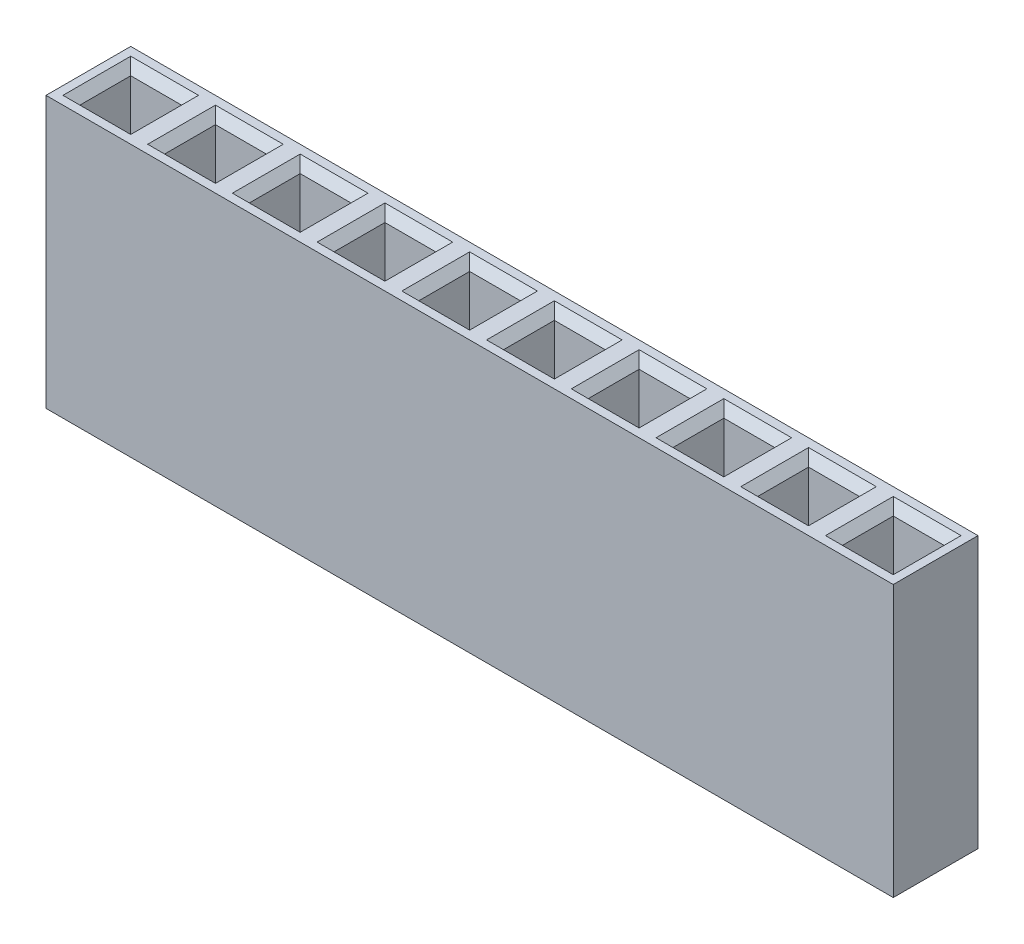
from build123d import *

# Parameters (mm, degrees)
SKETCH1_W                  = 2.5
SKETCH1_H                  = 8
BOSS_EXTRUDE1_DEPTH        = 2.5
SKETCH2_W                  = 1.5
SKETCH2_H                  = 1.5
CUT_EXTRUDE2_DEPTH         = 7
CHAMFER3_SIZE              = 0.25
LPATTERN2_COUNT            = 10
LPATTERN2_PITCH            = 2.5
CHAMFER3_OF_LPATTERN2_SIZE = 0.25


with BuildPart() as part:
    # Sketch1 → Boss-Extrude1 (new body)
    with BuildSketch(Plane.XY):
        Rectangle(SKETCH1_W, SKETCH1_H)
    boss_extrude1 = extrude(amount=BOSS_EXTRUDE1_DEPTH)

    # Sketch2 → Cut-Extrude2 (cut)
    with BuildSketch(Plane(origin=(0, 4, 0), x_dir=(1, 0, 0), z_dir=(0, 1, 0))):
        with Locations((0, -1.25)):
            Rectangle(SKETCH2_W, SKETCH2_H)
    cut_extrude2 = extrude(amount=-CUT_EXTRUDE2_DEPTH, mode=Mode.SUBTRACT)

    # Chamfer3
    chamfer3_edges = [part.edges().sort_by_distance(p)[0] for p in [
        (0, 4, 2),
        (0.75, 4, 1.25),
        (0, 4, 0.5),
        (-0.75, 4, 1.25),
    ]]
    chamfer(chamfer3_edges, length=CHAMFER3_SIZE)

    # LPattern2: Boss-Extrude1, Cut-Extrude2 ×10
    with Locations(*[(i * LPATTERN2_PITCH, 0, 0) for i in range(1, LPATTERN2_COUNT)]):
        add(boss_extrude1)
        add(cut_extrude2, mode=Mode.SUBTRACT)

    # Chamfer3 of LPattern2
    chamfer3_of_lpattern2_edges = [part.edges().sort_by_distance(p)[0] for p in [
        (2.5, 4, 2),
        (3.25, 4, 1.25),
        (2.5, 4, 0.5),
        (1.75, 4, 1.25),
        (5, 4, 2),
        (5.75, 4, 1.25),
        (5, 4, 0.5),
        (4.25, 4, 1.25),
        (7.5, 4, 2),
        (8.25, 4, 1.25),
        (7.5, 4, 0.5),
        (6.75, 4, 1.25),
        (10, 4, 2),
        (10.75, 4, 1.25),
        (10, 4, 0.5),
        (9.25, 4, 1.25),
        (12.5, 4, 2),
        (13.25, 4, 1.25),
        (12.5, 4, 0.5),
        (11.75, 4, 1.25),
        (15, 4, 2),
        (15.75, 4, 1.25),
        (15, 4, 0.5),
        (14.25, 4, 1.25),
        (17.5, 4, 2),
        (18.25, 4, 1.25),
        (17.5, 4, 0.5),
        (16.75, 4, 1.25),
        (20, 4, 2),
        (20.75, 4, 1.25),
        (20, 4, 0.5),
        (19.25, 4, 1.25),
        (22.5, 4, 2),
        (23.25, 4, 1.25),
        (22.5, 4, 0.5),
        (21.75, 4, 1.25),
    ]]
    chamfer(chamfer3_of_lpattern2_edges, length=CHAMFER3_OF_LPATTERN2_SIZE)


solid = part.part
